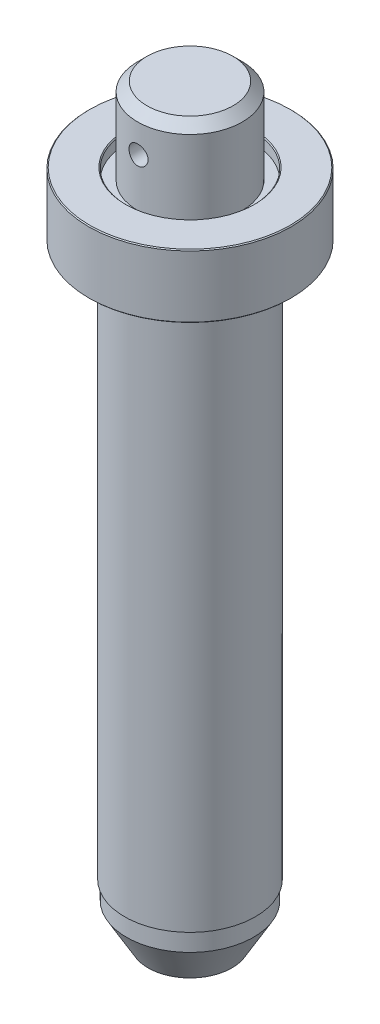
from build123d import *

# Parameters (mm, degrees)
CHAMFER1_SIZE      = 0.25
CHAMFER2_SIZE      = 0.25
CHAMFER3_SIZE      = 0.25
SKETCH2_R          = 2.55
CUT_EXTRUDE1_DEPTH = 15


with BuildPart() as part:
    # Sketch1 → Revolve1 (revolve)
    with BuildSketch(Plane.XY, mode=Mode.PRIVATE) as revolve1_sk:
        with BuildLine():
            Line((17.5, 15), (17.5, 158))
            ThreePointArc((17.5, 158), (18.964466094, 161.535533906), (22.5, 163))
            Line((22.5, 163), (27.1, 163))
            Line((27.1, 163), (27.1, 180))
            Line((27.1, 180), (17, 180))
            Line((17, 180), (17, 177))
            Line((17, 177), (14, 177))
            Line((14, 177), (14, 197.5))
            Line((14, 197.5), (11.5, 200))
            Line((11.5, 200), (0, 200))
            Line((0, 200), (0, 0))
            Line((0, 0), (11.226497308, 0))
            Line((11.226497308, 0), (17, 10))
            Line((17, 10), (17, 15))
            Line((17, 15), (17.5, 15))
        make_face()
    revolve(revolve1_sk.sketch.rotate(Axis((0, 0, 0), (0, 1, 0)), 90), axis=Axis((0, 0, 0), (0, 1, 0)))  # turned: the seam where the file's is

    # Chamfer1
    chamfer1_edges = [part.edges().sort_by_distance(p)[0] for p in [
        (0, 180, 27.1),
    ]]
    chamfer(chamfer1_edges, length=CHAMFER1_SIZE)

    # Chamfer2
    chamfer2_edges = [part.edges().sort_by_distance(p)[0] for p in [
        (0, 163, 27.1),
    ]]
    chamfer(chamfer2_edges, length=CHAMFER2_SIZE)

    # Chamfer3
    chamfer3_edges = [part.edges().sort_by_distance(p)[0] for p in [
        (0, 180, 17),
    ]]
    chamfer(chamfer3_edges, length=CHAMFER3_SIZE)

    # Sketch2 → Cut-Extrude1 (cut, symmetric)
    with BuildSketch(Plane.XY):
        with Locations((0, 189.875)):
            Circle(SKETCH2_R)
    extrude(amount=CUT_EXTRUDE1_DEPTH, both=True, mode=Mode.SUBTRACT)


solid = part.part
